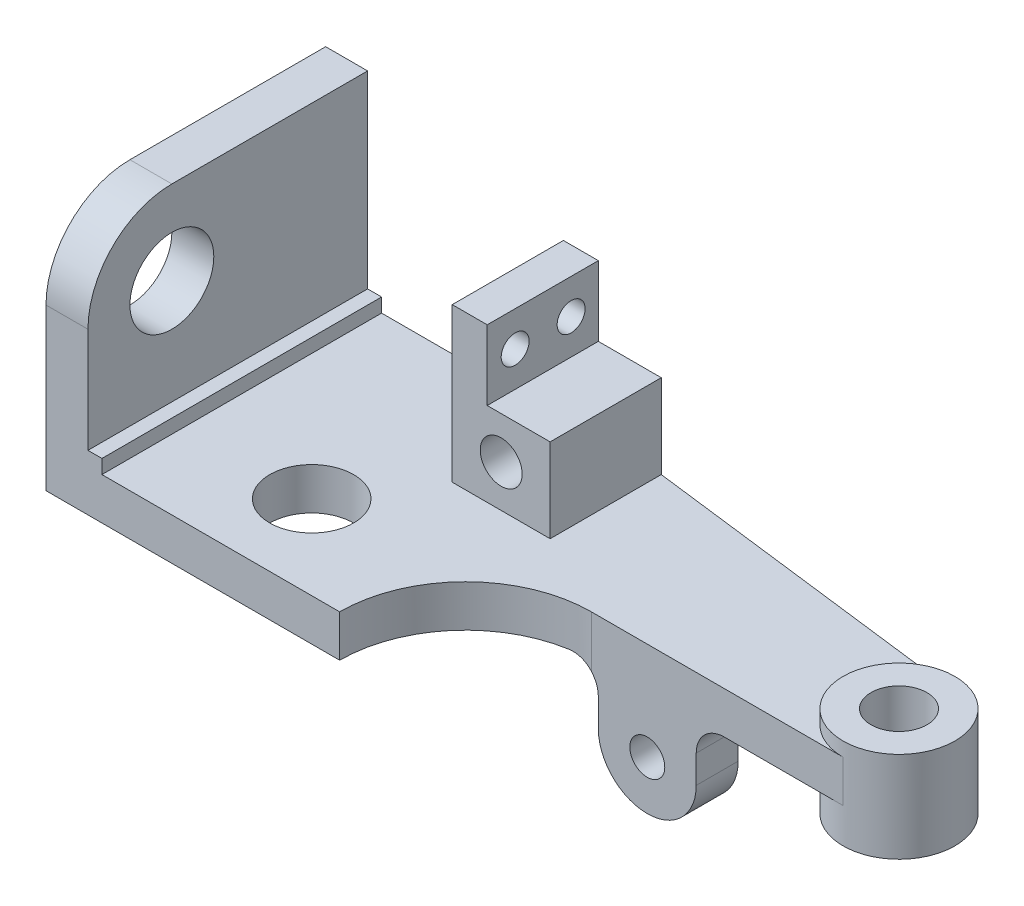
from build123d import *

# Parameters (mm, degrees)
CROQUIS1_R              = 9.525
SALIENTE_EXTRUIR1_DEPTH = 9.525
CROQUIS2_W              = 9.525
CROQUIS2_H              = 63.5
SALIENTE_EXTRUIR3_DEPTH = 46.0375
CROQUIS3_R              = 9.525
CORTAR_EXTRUIR1_DEPTH   = 46.0375
CROQUIS4_R              = 12.7
SALIENTE_EXTRUIR4_DEPTH = 3.175
CROQUIS5_W              = 22.225
CROQUIS5_H              = 25.233673581
SALIENTE_EXTRUIR5_DEPTH = 19.05
CROQUIS6_W              = 7.9375
CROQUIS6_H              = 25.233673581
SALIENTE_EXTRUIR6_DEPTH = 15.875
CROQUIS7_R              = 3.175
CORTAR_EXTRUIR2_DEPTH   = 15.875
CROQUIS8_R              = 4.7625
CORTAR_EXTRUIR4_DEPTH   = 26.233673581
CROQUIS9_R              = 12.7
SALIENTE_EXTRUIR7_DEPTH = 7.9375
CROQUIS10_R             = 6.35
CORTAR_EXTRUIR5_DEPTH   = 21.6375
CROQUIS14_W             = 22.225
CROQUIS14_H             = 9.525
SALIENTE_EXTRUIR8_DEPTH = 23.8125
CROQUIS15_R             = 3.96875
CORTAR_EXTRUIR7_DEPTH   = 35.925
REDONDEO6_R             = 6.35
CROQUIS16_W             = 3.175
CROQUIS16_H             = 3.175
SALIENTE_EXTRUIR9_DEPTH = 63.5


with BuildPart() as part:
    # Croquis1 → Saliente-Extruir1 (new body)
    with BuildSketch(Plane(origin=(0, 0, 0), x_dir=(1, 0, 0), z_dir=(0, 1, 0))):
        with BuildLine():
            Line((0, 0), (66.675, 0))
            ThreePointArc((66.675, 0), (75.044423728, 20.205576272), (95.25, 28.575))
            Line((95.25, 28.575), (152.4, 28.575))
            ThreePointArc((152.4, 28.575), (165.1, 41.275), (152.4, 53.975))
            Line((152.4, 53.975), (76.2, 63.5))
            Line((76.2, 63.5), (61.9125, 63.5))
            Line((61.9125, 63.5), (9.525, 63.5))
            Line((9.525, 63.5), (0, 63.5))
            Line((0, 63.5), (0, 0))
        make_face()
        with Locations((41.275, 19.05)):
            Circle(CROQUIS1_R, mode=Mode.SUBTRACT)
    extrude(amount=SALIENTE_EXTRUIR1_DEPTH)

    # Croquis2 → Saliente-Extruir3 (add)
    with BuildSketch(Plane(origin=(0, 9.525, 0), x_dir=(1, 0, 0), z_dir=(0, 1, 0))):
        with Locations((4.7625, 31.75)):
            Rectangle(CROQUIS2_W, CROQUIS2_H)
    extrude(amount=SALIENTE_EXTRUIR3_DEPTH)

    # Croquis3 → Cortar-Extruir1 (cut)
    with BuildSketch(Plane(origin=(9.525, 0, 0), x_dir=(0, 0, -1), z_dir=(1, 0, 0))):
        with Locations((19.05, 36.5125)):
            Circle(CROQUIS3_R)
        with BuildLine():
            Line((0, 55.5625), (0, 36.5125))
            ThreePointArc((0, 36.5125), (5.579615818, 49.982884182), (19.05, 55.5625))
            Line((19.05, 55.5625), (0, 55.5625))
        make_face()
    extrude(amount=-CORTAR_EXTRUIR1_DEPTH, mode=Mode.SUBTRACT)

    # Croquis4 → Saliente-Extruir4 (add)
    with BuildSketch(Plane(origin=(0, 9.525, 0), x_dir=(1, 0, 0), z_dir=(0, 1, 0))):
        with Locations((152.4, 41.275)):
            Circle(CROQUIS4_R)
    extrude(amount=SALIENTE_EXTRUIR4_DEPTH)

    # Croquis5 → Saliente-Extruir5 (add)
    with BuildSketch(Plane(origin=(0, 9.525, 0), x_dir=(1, 0, 0), z_dir=(0, 1, 0))):
        with Locations((65.0875, 50.88316321)):
            Rectangle(CROQUIS5_W, CROQUIS5_H)
    extrude(amount=SALIENTE_EXTRUIR5_DEPTH)

    # Croquis6 → Saliente-Extruir6 (add)
    with BuildSketch(Plane(origin=(0, 28.575, 0), x_dir=(1, 0, 0), z_dir=(0, 1, 0))):
        with Locations((57.94375, 50.88316321)):
            Rectangle(CROQUIS6_W, CROQUIS6_H)
    extrude(amount=SALIENTE_EXTRUIR6_DEPTH)

    # Croquis7 → Cortar-Extruir2 (cut)
    with BuildSketch(Plane(origin=(61.9125, 0, 0), x_dir=(0, 0, -1), z_dir=(1, 0, 0))):
        with Locations((44.616326419, 36.5125)):
            Circle(CROQUIS7_R)
        with Locations((57.316326419, 36.5125)):
            Circle(CROQUIS7_R)
    extrude(amount=-CORTAR_EXTRUIR2_DEPTH, mode=Mode.SUBTRACT)

    # Croquis8 → Cortar-Extruir4 (cut, through all)
    with BuildSketch(Plane.XY.offset(-38.266326419)):
        with Locations((65.0875, 19.05)):
            Circle(CROQUIS8_R)
    extrude(amount=-CORTAR_EXTRUIR4_DEPTH, mode=Mode.SUBTRACT)

    # Croquis9 → Saliente-Extruir7 (add)
    with BuildSketch(Plane.XZ):
        with Locations((152.4, -41.275)):
            Circle(CROQUIS9_R)
    extrude(amount=SALIENTE_EXTRUIR7_DEPTH)

    # Croquis10 → Cortar-Extruir5 (cut, through all)
    with BuildSketch(Plane(origin=(0, 12.7, 0), x_dir=(1, 0, 0), z_dir=(0, 1, 0))):
        with Locations((152.4, 41.275)):
            Circle(CROQUIS10_R)
    extrude(amount=-CORTAR_EXTRUIR5_DEPTH, mode=Mode.SUBTRACT)

    # Croquis14 → Saliente-Extruir8 (add)
    with BuildSketch(Plane.XZ):
        with Locations((107.95, -33.3375)):
            Rectangle(CROQUIS14_W, CROQUIS14_H)
    extrude(amount=SALIENTE_EXTRUIR8_DEPTH)

    # Croquis15 → Cortar-Extruir7 (cut, through all)
    with BuildSketch(Plane.XY.offset(-28.575)):
        with Locations((107.95, -12.7)):
            Circle(CROQUIS15_R)
        with BuildLine():
            ThreePointArc((119.0625, -12.7), (115.807724106, -20.557724106), (107.95, -23.8125))
            Line((107.95, -23.8125), (119.0625, -23.8125))
            Line((119.0625, -23.8125), (119.0625, -12.7))
        make_face()
        with BuildLine():
            ThreePointArc((107.95, -23.8125), (100.092275894, -20.557724106), (96.8375, -12.7))
            Line((96.8375, -12.7), (96.8375, -23.8125))
            Line((96.8375, -23.8125), (107.95, -23.8125))
        make_face()
    extrude(amount=-CORTAR_EXTRUIR7_DEPTH, mode=Mode.SUBTRACT)

    # Redondeo6
    redondeo6_edges = [part.edges().sort_by_distance(p)[0] for p in [
        (119.0625, 0, -33.3375),
        (96.8375, 0, -33.3375),
    ]]
    fillet(redondeo6_edges, radius=REDONDEO6_R)

    # Croquis16 → Saliente-Extruir9 (add)
    with BuildSketch(Plane.XY):
        with Locations((11.1125, 11.1125)):
            Rectangle(CROQUIS16_W, CROQUIS16_H)
    extrude(amount=-SALIENTE_EXTRUIR9_DEPTH)


solid = part.part
